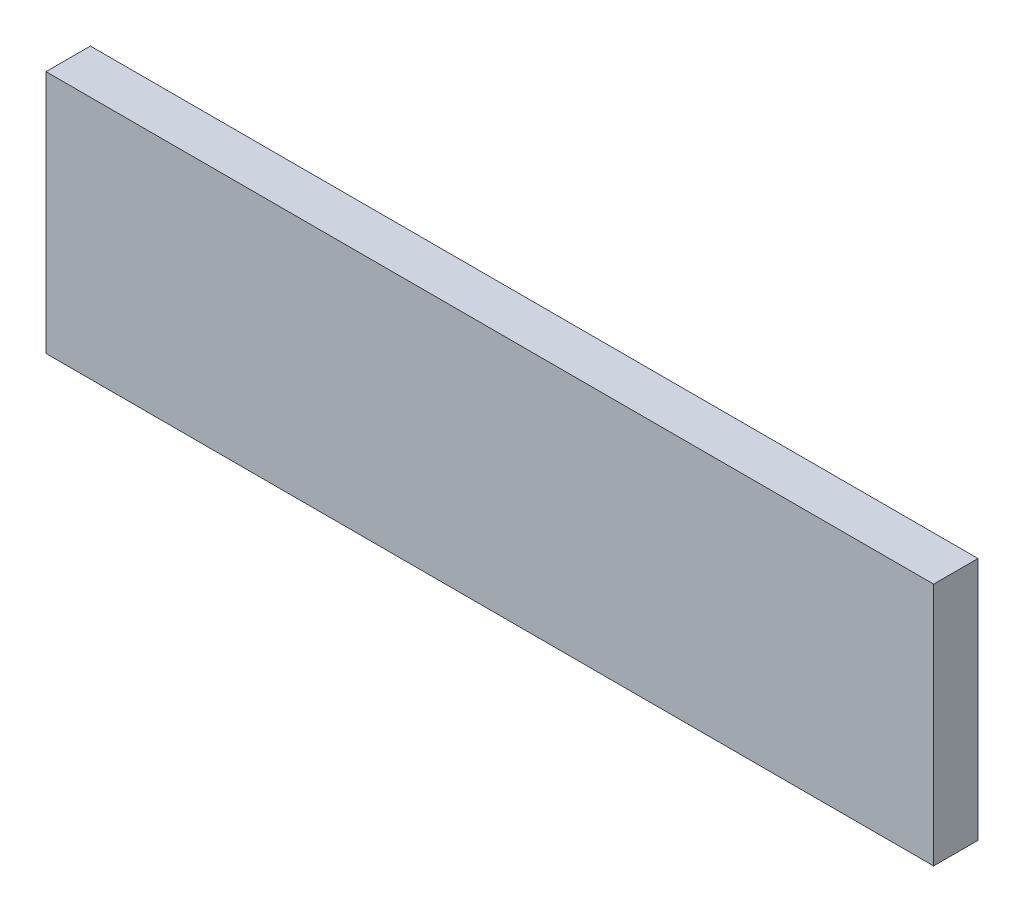
from build123d import *

# Parameters (mm, degrees)
SKETCH1_W           = 2000
SKETCH1_H           = 550
BOSS_EXTRUDE1_DEPTH = 100


with BuildPart() as part:
    # Sketch1 → Boss-Extrude1 (new body)
    with BuildSketch(Plane.XY):
        with Locations((-1000, -275)):
            Rectangle(SKETCH1_W, SKETCH1_H)
    extrude(amount=BOSS_EXTRUDE1_DEPTH)


solid = part.part
